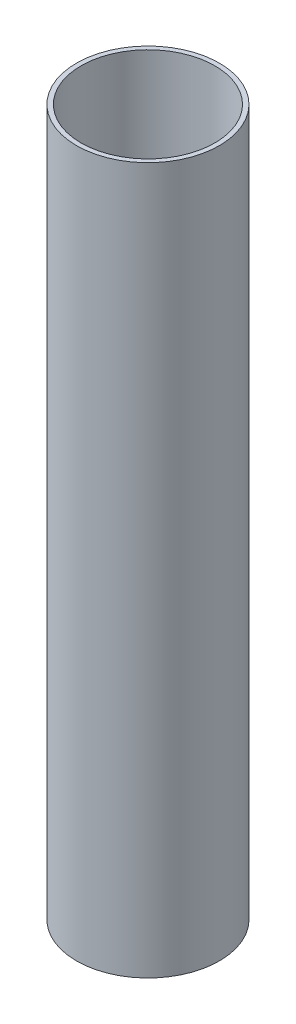
from build123d import *

# Parameters (mm, degrees)
SKETCH1_R           = 25
SKETCH1_R_2         = 23.4
BOSS_EXTRUDE1_DEPTH = 247


with BuildPart() as part:
    # Sketch1 → Boss-Extrude1 (new body)
    with BuildSketch(Plane(origin=(0, 0, 0), x_dir=(1, 0, 0), z_dir=(0, 1, 0))):
        Circle(SKETCH1_R)
        Circle(SKETCH1_R_2, mode=Mode.SUBTRACT)
    extrude(amount=BOSS_EXTRUDE1_DEPTH)


solid = part.part
